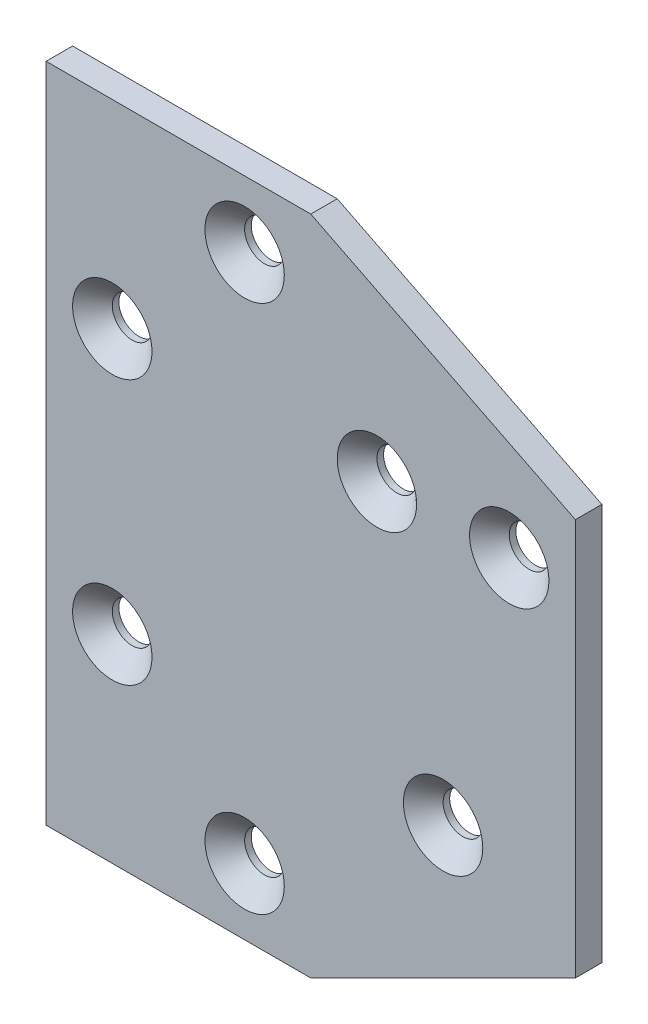
from build123d import *

# Parameters (mm, degrees)
SKETCH1_W           = 40
SKETCH1_H           = 100
SKETCH1_H_2         = 60
BOSS_EXTRUDE1_DEPTH = 2
SKETCH2_R           = 3
CUT_EXTRUDE1_DEPTH  = 5
CHAMFER1_SIZE       = 3


with BuildPart() as part:
    # Sketch1 → Boss-Extrude1 (new body, symmetric)
    with BuildSketch(Plane.XY):
        Rectangle(SKETCH1_W, SKETCH1_H)
        Polygon((60, 30), (20, 50), (20, 30), align=None)
        with Locations((40, 0)):
            Rectangle(SKETCH1_W, SKETCH1_H_2)
        Polygon((20, -50), (60, -30), (20, -30), align=None)
    extrude(amount=BOSS_EXTRUDE1_DEPTH, both=True)

    # Sketch2 → Cut-Extrude1 (cut, through all)
    with BuildSketch(Plane.XY.offset(2)):
        with Locations((-10, 20)):
            Circle(SKETCH2_R)
        with Locations((-10, -20)):
            Circle(SKETCH2_R)
        with Locations((10, -40)):
            Circle(SKETCH2_R)
        with Locations((40, -20)):
            Circle(SKETCH2_R)
        with Locations((30, 20)):
            Circle(SKETCH2_R)
        with Locations((50, 20)):
            Circle(SKETCH2_R)
        with Locations((10, 40)):
            Circle(SKETCH2_R)
    extrude(amount=-CUT_EXTRUDE1_DEPTH, mode=Mode.SUBTRACT)

    # Chamfer1
    chamfer1_edges = [part.edges().sort_by_distance(p)[0] for p in [
        (37, -20, 2),
        (7, -40, 2),
        (-13, -20, 2),
        (7, 40, 2),
        (27, 20, 2),
        (47, 20, 2),
        (-13, 20, 2),
    ]]
    chamfer(chamfer1_edges, length=CHAMFER1_SIZE)


solid = part.part
